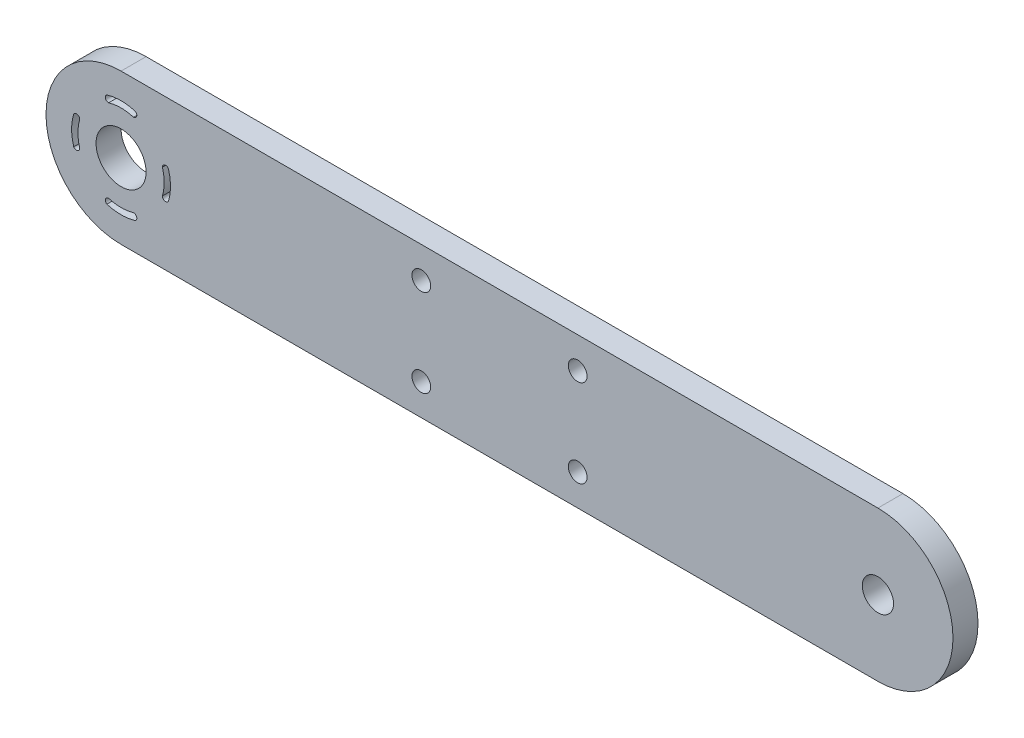
from build123d import *

# Parameters (mm, degrees)
SKETCH1_R           = 4
SKETCH1_R_2         = 1.5
SKETCH1_R_3         = 2.5
BOSS_EXTRUDE1_DEPTH = 4


with BuildPart() as part:
    # Sketch1 → Boss-Extrude1 (new body)
    with BuildSketch(Plane.XY):
        with BuildLine():
            Line((12.000000461, 24.00000011), (133.000000461, 24.00000011))
            ThreePointArc((133.000000461, 24.00000011), (145.000000461, 12.00000011), (133.000000461, 1.1e-07))
            Line((133.000000461, 1.1e-07), (12.000000461, 1.1e-07))
            ThreePointArc((12.000000461, 1.1e-07), (4.61e-07, 12.00000011), (12.000000461, 24.00000011))
        make_face()
        with Locations((12.000000461, 12.00000011)):
            Circle(SKETCH1_R, mode=Mode.SUBTRACT)
        with Locations((60.000000461, 5.00000011)):
            Circle(SKETCH1_R_2, mode=Mode.SUBTRACT)
        with Locations((60.000000461, 19.00000011)):
            Circle(SKETCH1_R_2, mode=Mode.SUBTRACT)
        with Locations((85.000000461, 5.00000011)):
            Circle(SKETCH1_R_2, mode=Mode.SUBTRACT)
        with Locations((85.000000461, 19.00000011)):
            Circle(SKETCH1_R_2, mode=Mode.SUBTRACT)
        with Locations((133.000000461, 12.00000011)):
            Circle(SKETCH1_R_3, mode=Mode.SUBTRACT)
        with BuildLine():
            ThreePointArc((9.729668922, 4.433322836), (12.000000461, 4.100062751), (14.270331999, 4.433322836))
            ThreePointArc((14.270331999, 4.433322836), (14.500023689, 5.017172326), (14.000000461, 5.396138381))
            ThreePointArc((14.000000461, 5.396138381), (12.000000461, 5.09992839), (10.000000461, 5.396138381))
            ThreePointArc((10.000000461, 5.396138381), (9.499977232, 5.017172326), (9.729668922, 4.433322836))
        make_face(mode=Mode.SUBTRACT)
        with BuildLine():
            ThreePointArc((19.566677735, 9.729668571), (19.899937819, 12.00000011), (19.566677735, 14.270331648))
            ThreePointArc((19.566677735, 14.270331648), (18.982828244, 14.500023338), (18.603862189, 14.00000011))
            ThreePointArc((18.603862189, 14.00000011), (18.90007218, 12.00000011), (18.603862189, 10.00000011))
            ThreePointArc((18.603862189, 10.00000011), (18.982828244, 9.499976882), (19.566677735, 9.729668571))
        make_face(mode=Mode.SUBTRACT)
        with BuildLine():
            ThreePointArc((14.270331999, 19.566677384), (12.000000461, 19.899937468), (9.729668922, 19.566677384))
            ThreePointArc((9.729668922, 19.566677384), (9.499977232, 18.982827894), (10.000000461, 18.603861839))
            ThreePointArc((10.000000461, 18.603861839), (12.000000461, 18.900071829), (14.000000461, 18.603861839))
            ThreePointArc((14.000000461, 18.603861839), (14.500023689, 18.982827894), (14.270331999, 19.566677384))
        make_face(mode=Mode.SUBTRACT)
        with BuildLine():
            ThreePointArc((4.433323186, 14.270331648), (4.100063102, 12.00000011), (4.433323186, 9.729668571))
            ThreePointArc((4.433323186, 9.729668571), (5.017172677, 9.499976882), (5.396138732, 10.00000011))
            ThreePointArc((5.396138732, 10.00000011), (5.099928741, 12.00000011), (5.396138732, 14.00000011))
            ThreePointArc((5.396138732, 14.00000011), (5.017172677, 14.500023338), (4.433323186, 14.270331648))
        make_face(mode=Mode.SUBTRACT)
    extrude(amount=BOSS_EXTRUDE1_DEPTH)


solid = part.part
